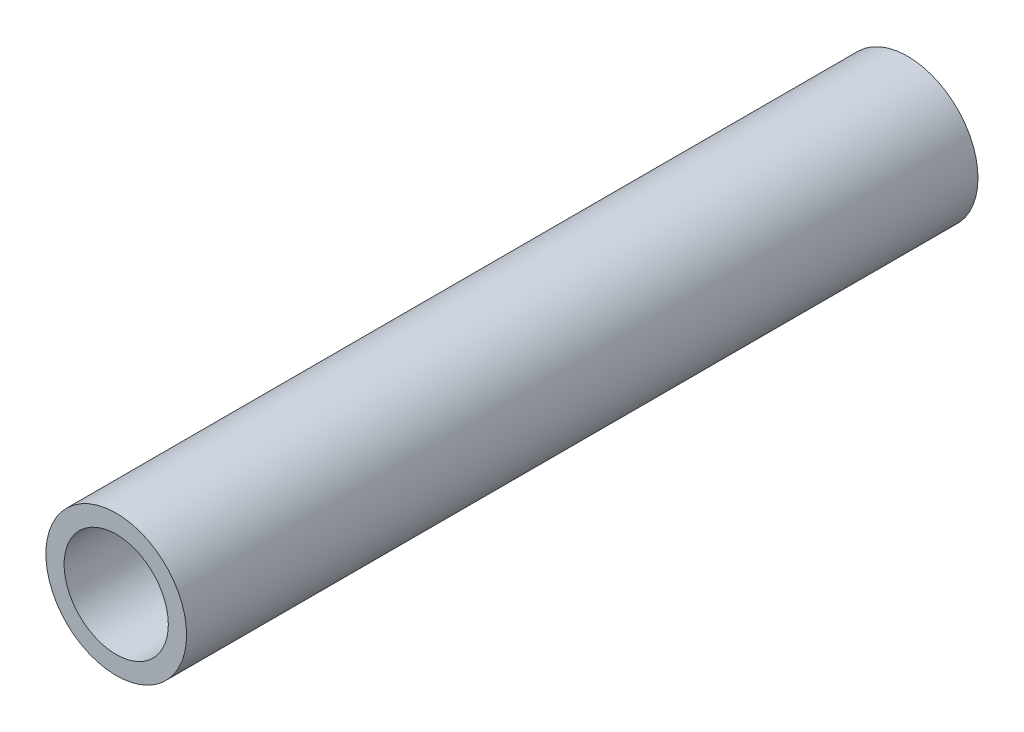
from build123d import *

# Parameters (mm, degrees)
SKETCH1_R           = 10.668
SKETCH1_R_2         = 7.8994
EXTRUDE_THIN1_DEPTH = 60


with BuildPart() as part:
    # Sketch1 → Extrude-Thin1 (new body, symmetric)
    with BuildSketch(Plane.XY):
        Circle(SKETCH1_R)
        Circle(SKETCH1_R_2, mode=Mode.SUBTRACT)
    extrude(amount=EXTRUDE_THIN1_DEPTH, both=True)


solid = part.part
